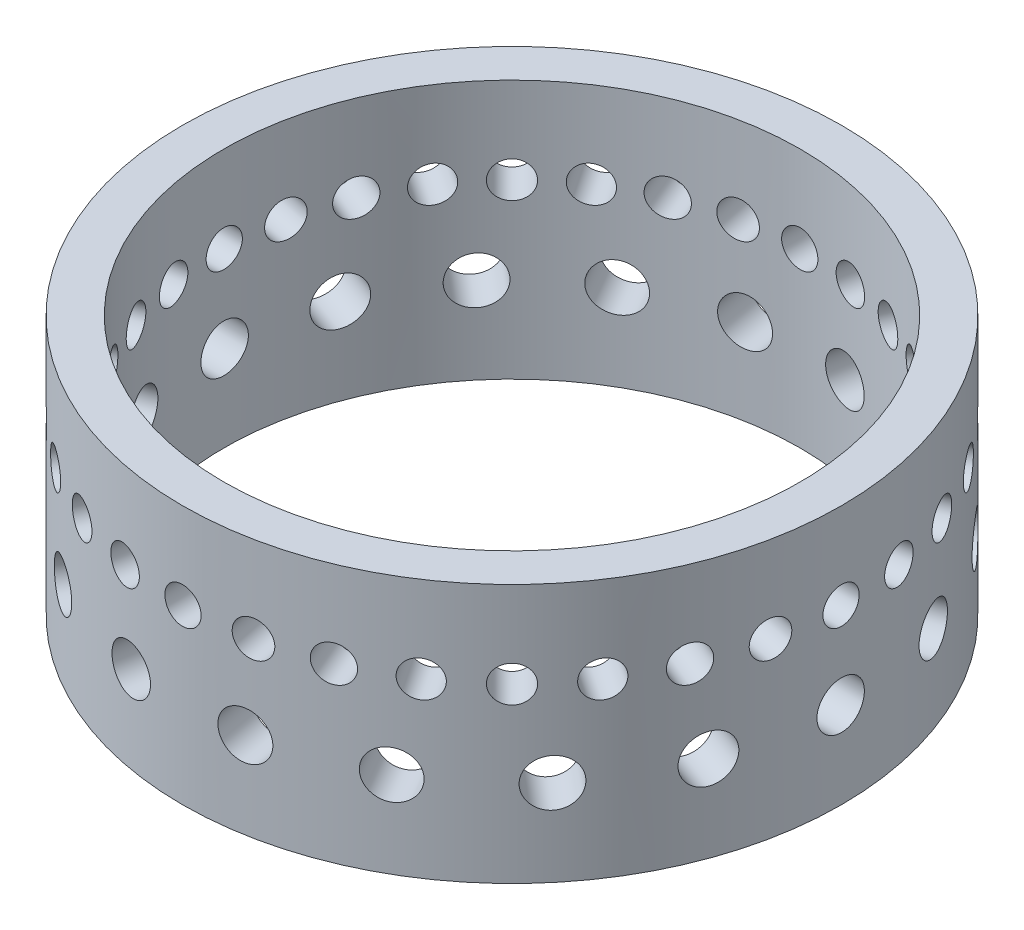
from build123d import *

# Parameters (mm, degrees)
SKETCH1_R           = 25.4
SKETCH1_R_2         = 22.225
BOSS_EXTRUDE1_DEPTH = 19.9644
SKETCH2_R           = 1.8288
CUT_EXTRUDE1_DEPTH  = 35.4584
CIRPATTERN1_COUNT   = 18
SKETCH4_R           = 1.397
CUT_EXTRUDE2_DEPTH  = 35.4584
CIRPATTERN2_COUNT   = 32


with BuildPart() as part:
    # Sketch1 → Boss-Extrude1 (new body)
    with BuildSketch(Plane(origin=(0, 0, 0), x_dir=(1, 0, 0), z_dir=(0, 1, 0))):
        Circle(SKETCH1_R)
        Circle(SKETCH1_R_2, mode=Mode.SUBTRACT)
    extrude(amount=BOSS_EXTRUDE1_DEPTH)

    # Sketch2 → Cut-Extrude1 (cut)
    with BuildSketch(Plane(origin=(0, 0, 0), x_dir=(0, 0, -1), z_dir=(1, 0, 0))):
        with Locations((0, 6.6548)):
            Circle(SKETCH2_R)
    cut_extrude1 = extrude(amount=-CUT_EXTRUDE1_DEPTH, mode=Mode.SUBTRACT)

    # CirPattern1: Cut-Extrude1 ×18 about axis
    cirpattern1_axis = Axis((0, 0, 0), (0, 1, 0))
    for i in range(1, CIRPATTERN1_COUNT):
        add(cut_extrude1.rotate(cirpattern1_axis, i * 360 / CIRPATTERN1_COUNT), mode=Mode.SUBTRACT)

    # Sketch4 → Cut-Extrude2 (cut)
    with BuildSketch(Plane(origin=(0, 0, 0), x_dir=(0, 0, -1), z_dir=(1, 0, 0))):
        with Locations((0, 13.3096)):
            Circle(SKETCH4_R)
    cut_extrude2 = extrude(amount=-CUT_EXTRUDE2_DEPTH, mode=Mode.SUBTRACT)

    # CirPattern2: Cut-Extrude2 ×32 about axis
    cirpattern2_axis = Axis((0, 0, 0), (0, 1, 0))
    for i in range(1, CIRPATTERN2_COUNT):
        add(cut_extrude2.rotate(cirpattern2_axis, i * 360 / CIRPATTERN2_COUNT), mode=Mode.SUBTRACT)


solid = part.part
